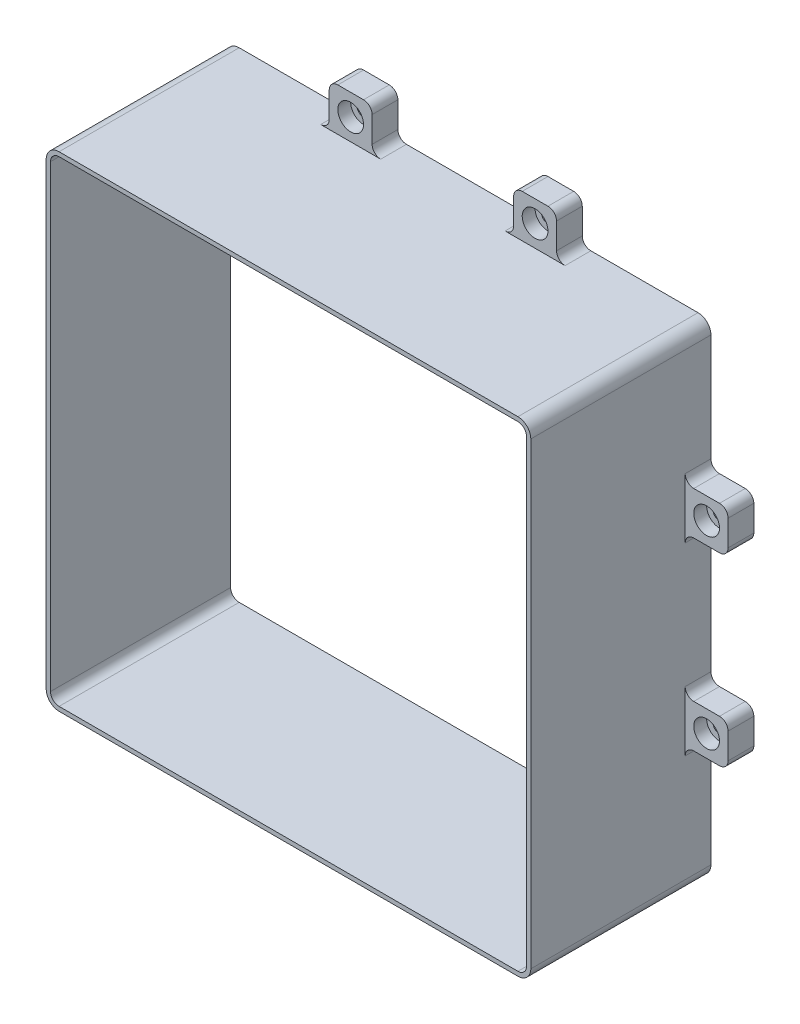
from build123d import *

# Parameters (mm, degrees)
P_IDAT_VYSUNUT_M1_DEPTH      = 42
SKICA7_W                     = 10
SKICA7_H                     = 6
P_IDAT_VYSUNUT_M2_DEPTH      = 10
SKICA8_R                     = 3
ODEBRAT_VYSUNUT_M4_DEPTH     = 3
SKICA9_R                     = 1.55
ODEBRAT_VYSUNUT_M5_DEPTH     = 3
LINPOLE1_COUNT               = 2
LINPOLE1_PITCH               = 43
KRUHOV_POLE1_COUNT           = 4
KRUHOV_POLE1_COPY_1_SKETCH_W = 10
KRUHOV_POLE1_COPY_1_SKETCH_H = 6
KRUHOV_POLE1_COPY_1_DEPTH    = 10
KRUHOV_POLE1_COPY_2_SKETCH_W = 10
KRUHOV_POLE1_COPY_2_SKETCH_H = 6
KRUHOV_POLE1_COPY_2_DEPTH    = 10
KRUHOV_POLE1_COPY_3_SKETCH_W = 10
KRUHOV_POLE1_COPY_3_SKETCH_H = 6
KRUHOV_POLE1_COPY_3_DEPTH    = 10
KRUHOV_POLE1_COPY_4_SKETCH_R = 3
KRUHOV_POLE1_COPY_4_DEPTH    = 3
KRUHOV_POLE1_COPY_5_SKETCH_R = 3
KRUHOV_POLE1_COPY_5_DEPTH    = 3
KRUHOV_POLE1_COPY_6_SKETCH_R = 3
KRUHOV_POLE1_COPY_6_DEPTH    = 3
KRUHOV_POLE1_COPY_7_SKETCH_R = 1.55
KRUHOV_POLE1_COPY_7_DEPTH    = 3
KRUHOV_POLE1_COPY_8_SKETCH_R = 1.55
KRUHOV_POLE1_COPY_8_DEPTH    = 3
KRUHOV_POLE1_COPY_9_SKETCH_R = 1.55
KRUHOV_POLE1_COPY_9_DEPTH    = 3
ZAOBLIT3_R                   = 2


with BuildPart() as part:
    # Skica2 → Přidat vysunutím1 (new body)
    with BuildSketch(Plane.XY):
        with BuildLine():
            Line((3, 0), (110, 0))
            ThreePointArc((110, 0), (112.121320344, -0.878679656), (113, -3))
            Line((113, -3), (113, -110))
            ThreePointArc((113, -110), (112.121320344, -112.121320344), (110, -113))
            Line((110, -113), (3, -113))
            ThreePointArc((3, -113), (0.878679656, -112.121320344), (0, -110))
            Line((0, -110), (0, -3))
            ThreePointArc((0, -3), (0.878679656, -0.878679656), (3, 0))
        make_face()
        with BuildLine():
            Line((1, -3), (1, -110))
            ThreePointArc((1, -110), (1.585786438, -111.414213562), (3, -112))
            Line((3, -112), (110, -112))
            ThreePointArc((110, -112), (111.414213562, -111.414213562), (112, -110))
            Line((112, -110), (112, -3))
            ThreePointArc((112, -3), (111.414213562, -1.585786438), (110, -1))
            Line((110, -1), (3, -1))
            ThreePointArc((3, -1), (1.585786438, -1.585786438), (1, -3))
        make_face(mode=Mode.SUBTRACT)
    extrude(amount=P_IDAT_VYSUNUT_M1_DEPTH)

    # Skica7 → Přidat vysunutím2 (add)
    with BuildSketch(Plane(origin=(0, 0, 0), x_dir=(1, 0, 0), z_dir=(0, 1, 0))):
        with Locations((35, -3)):
            Rectangle(SKICA7_W, SKICA7_H)
    p_idat_vysunut_m2 = extrude(amount=P_IDAT_VYSUNUT_M2_DEPTH)

    # Skica8 → Odebrat vysunutím4 (cut)
    with BuildSketch(Plane.XY.offset(6)):
        with Locations((35, 5)):
            Circle(SKICA8_R)
    odebrat_vysunut_m4 = extrude(amount=-ODEBRAT_VYSUNUT_M4_DEPTH, mode=Mode.SUBTRACT)

    # Skica9 → Odebrat vysunutím5 (cut)
    with BuildSketch(Plane.XY.offset(3)):
        with Locations((35, 5)):
            Circle(SKICA9_R)
    odebrat_vysunut_m5 = extrude(amount=-ODEBRAT_VYSUNUT_M5_DEPTH, mode=Mode.SUBTRACT)

    # LinPole1: Přidat vysunutím2, Odebrat vysunutím4, Odebrat vysunutím5 ×2
    with Locations(*[(i * LINPOLE1_PITCH, 0, 0) for i in range(1, LINPOLE1_COUNT)]):
        add(p_idat_vysunut_m2)
        add(odebrat_vysunut_m4, mode=Mode.SUBTRACT)
        add(odebrat_vysunut_m5, mode=Mode.SUBTRACT)

    # Kruhové pole1: Přidat vysunutím2, Odebrat vysunutím4, Odebrat vysunutím5 ×4 about axis
    kruhov_pole1_axis = Axis((56.5, -56.5, 0), (0, 0, 1))
    for i in range(1, KRUHOV_POLE1_COUNT):
        add(p_idat_vysunut_m2.rotate(kruhov_pole1_axis, i * 360 / KRUHOV_POLE1_COUNT))
        add(odebrat_vysunut_m4.rotate(kruhov_pole1_axis, i * 360 / KRUHOV_POLE1_COUNT), mode=Mode.SUBTRACT)
        add(odebrat_vysunut_m5.rotate(kruhov_pole1_axis, i * 360 / KRUHOV_POLE1_COUNT), mode=Mode.SUBTRACT)

    # Kruhové pole1 copy 1 sketch → Kruhové pole1 copy 1 (add)
    with BuildSketch(Plane(origin=(0, -70, 0), x_dir=(0, 1, 0), z_dir=(-1, 0, 0))):
        with Locations((35, -3)):
            Rectangle(KRUHOV_POLE1_COPY_1_SKETCH_W, KRUHOV_POLE1_COPY_1_SKETCH_H)
    extrude(amount=KRUHOV_POLE1_COPY_1_DEPTH)

    # Kruhové pole1 copy 2 sketch → Kruhové pole1 copy 2 (add)
    with BuildSketch(Plane(origin=(70, -113, 0), x_dir=(-1, 0, 0), z_dir=(0, -1, 0))):
        with Locations((35, -3)):
            Rectangle(KRUHOV_POLE1_COPY_2_SKETCH_W, KRUHOV_POLE1_COPY_2_SKETCH_H)
    extrude(amount=KRUHOV_POLE1_COPY_2_DEPTH)

    # Kruhové pole1 copy 3 sketch → Kruhové pole1 copy 3 (add)
    with BuildSketch(Plane(origin=(113, -43, 0), x_dir=(0, -1, 0), z_dir=(1, 0, 0))):
        with Locations((35, -3)):
            Rectangle(KRUHOV_POLE1_COPY_3_SKETCH_W, KRUHOV_POLE1_COPY_3_SKETCH_H)
    extrude(amount=KRUHOV_POLE1_COPY_3_DEPTH)

    # Kruhové pole1 copy 4 sketch → Kruhové pole1 copy 4 (cut)
    with BuildSketch(Plane(origin=(0, -70, 6), x_dir=(0, 1, 0), z_dir=(0, 0, 1))):
        with Locations((35, 5)):
            Circle(KRUHOV_POLE1_COPY_4_SKETCH_R)
    extrude(amount=-KRUHOV_POLE1_COPY_4_DEPTH, mode=Mode.SUBTRACT)

    # Kruhové pole1 copy 5 sketch → Kruhové pole1 copy 5 (cut)
    with BuildSketch(Plane(origin=(70, -113, 6), x_dir=(-1, 0, 0), z_dir=(0, 0, 1))):
        with Locations((35, 5)):
            Circle(KRUHOV_POLE1_COPY_5_SKETCH_R)
    extrude(amount=-KRUHOV_POLE1_COPY_5_DEPTH, mode=Mode.SUBTRACT)

    # Kruhové pole1 copy 6 sketch → Kruhové pole1 copy 6 (cut)
    with BuildSketch(Plane(origin=(113, -43, 6), x_dir=(0, -1, 0), z_dir=(0, 0, 1))):
        with Locations((35, 5)):
            Circle(KRUHOV_POLE1_COPY_6_SKETCH_R)
    extrude(amount=-KRUHOV_POLE1_COPY_6_DEPTH, mode=Mode.SUBTRACT)

    # Kruhové pole1 copy 7 sketch → Kruhové pole1 copy 7 (cut)
    with BuildSketch(Plane(origin=(0, -70, 3), x_dir=(0, 1, 0), z_dir=(0, 0, 1))):
        with Locations((35, 5)):
            Circle(KRUHOV_POLE1_COPY_7_SKETCH_R)
    extrude(amount=-KRUHOV_POLE1_COPY_7_DEPTH, mode=Mode.SUBTRACT)

    # Kruhové pole1 copy 8 sketch → Kruhové pole1 copy 8 (cut)
    with BuildSketch(Plane(origin=(70, -113, 3), x_dir=(-1, 0, 0), z_dir=(0, 0, 1))):
        with Locations((35, 5)):
            Circle(KRUHOV_POLE1_COPY_8_SKETCH_R)
    extrude(amount=-KRUHOV_POLE1_COPY_8_DEPTH, mode=Mode.SUBTRACT)

    # Kruhové pole1 copy 9 sketch → Kruhové pole1 copy 9 (cut)
    with BuildSketch(Plane(origin=(113, -43, 3), x_dir=(0, -1, 0), z_dir=(0, 0, 1))):
        with Locations((35, 5)):
            Circle(KRUHOV_POLE1_COPY_9_SKETCH_R)
    extrude(amount=-KRUHOV_POLE1_COPY_9_DEPTH, mode=Mode.SUBTRACT)

    # Zaoblit3
    zaoblit3_edges = [part.edges().sort_by_distance(p)[0] for p in [
        (83, -113, 3),
        (73, -113, 3),
        (83, -123, 3),
        (73, -123, 3),
        (0, -83, 3),
        (0, -73, 3),
        (-10, -83, 3),
        (-10, -73, 3),
        (113, -73, 3),
        (113, -83, 3),
        (123, -73, 3),
        (123, -83, 3),
        (40, -113, 3),
        (30, -113, 3),
        (40, -123, 3),
        (30, -123, 3),
        (0, -40, 3),
        (0, -30, 3),
        (-10, -40, 3),
        (-10, -30, 3),
        (30, 0, 3),
        (40, 0, 3),
        (30, 10, 3),
        (40, 10, 3),
        (73, 0, 3),
        (83, 0, 3),
        (73, 10, 3),
        (83, 10, 3),
        (113, -30, 3),
        (113, -40, 3),
        (123, -30, 3),
        (123, -40, 3),
    ]]
    fillet(zaoblit3_edges, radius=ZAOBLIT3_R)


solid = part.part
